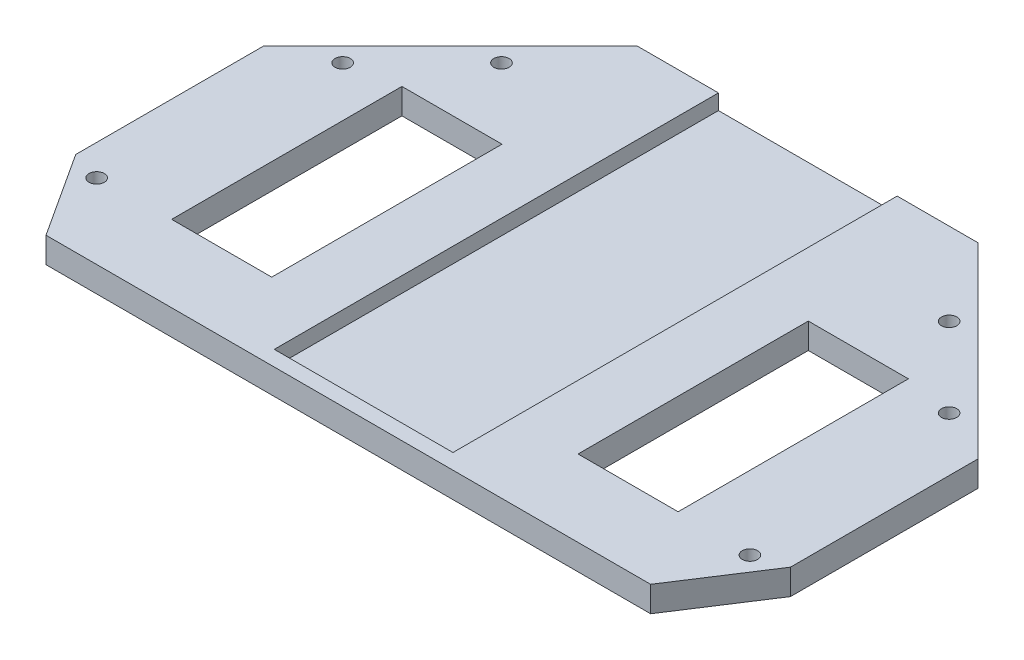
from build123d import *

# Parameters (mm, degrees)
SKETCH1_R           = 1.5
SKETCH1_W           = 19.6
SKETCH1_H           = 45.1
BOSS_EXTRUDE1_DEPTH = 5
SKETCH2_W           = 35
SKETCH2_H           = 87
CUT_EXTRUDE1_DEPTH  = 3


with BuildPart() as part:
    # Sketch1 → Boss-Extrude1 (new body)
    with BuildSketch(Plane(origin=(0, 0, 0), x_dir=(1, 0, 0), z_dir=(0, 1, 0))):
        Polygon((-59.213749531, -30), (-70, -13.390630812), (-70, 23.338095117), (-33.338095117, 60), (0, 60), (0, -30), align=None)
        with Locations((-43.840620434, 43.840620434)):
            Circle(SKETCH1_R, mode=Mode.SUBTRACT)
        with Locations((-59.39696962, 28.284271247)):
            Circle(SKETCH1_R, mode=Mode.SUBTRACT)
        with Locations((-63.979633983, -15.316867676)):
            Circle(SKETCH1_R, mode=Mode.SUBTRACT)
        with Locations((-39.8, 7.55)):
            Rectangle(SKETCH1_W, SKETCH1_H, mode=Mode.SUBTRACT)
    boss_extrude1 = extrude(amount=BOSS_EXTRUDE1_DEPTH)

    # Mirror1: Boss-Extrude1 across plane
    add(boss_extrude1.mirror(Plane(origin=(0, 5, 30), x_dir=(0, 0, 1), z_dir=(-1, 0, 0))))

    # Sketch2 → Cut-Extrude1 (cut)
    with BuildSketch(Plane(origin=(0, 5, 0), x_dir=(1, 0, 0), z_dir=(0, 1, 0))):
        with Locations((0, 16.5)):
            Rectangle(SKETCH2_W, SKETCH2_H)
    extrude(amount=-CUT_EXTRUDE1_DEPTH, mode=Mode.SUBTRACT)


solid = part.part
